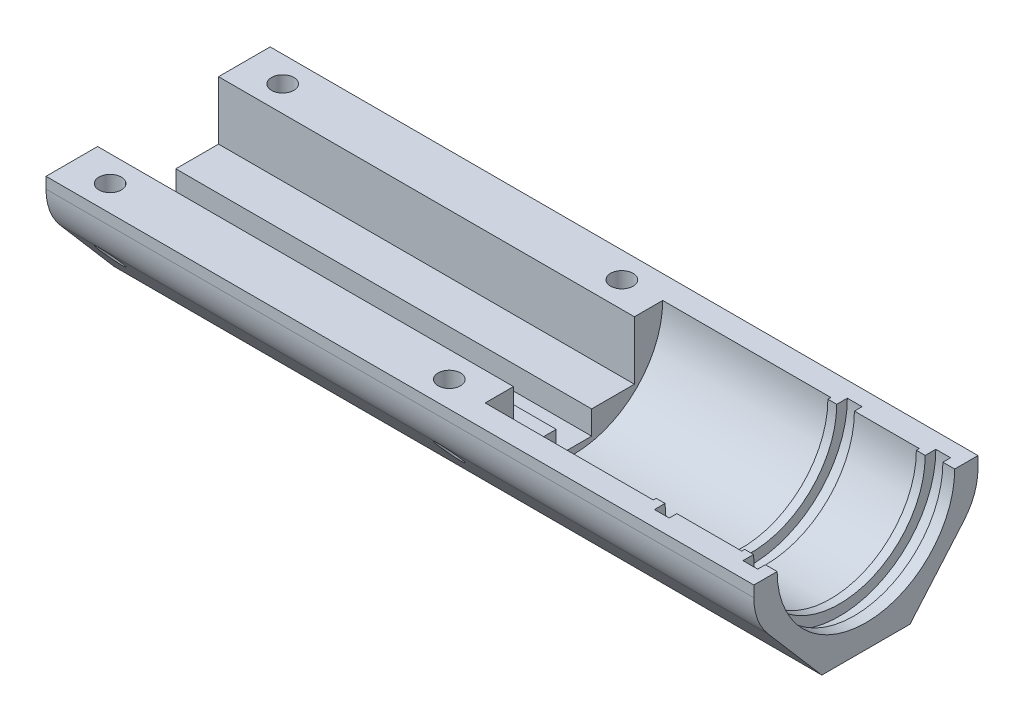
from build123d import *

# Parameters (mm, degrees)
R_VOLUTION1_ANGLE       = 180
ENL_V_START             = -19
ESQUISSE2_W             = 120
ESQUISSE2_H             = 50.1
ENL_V_MAT_EXTRU_1_DEPTH = 10
ESQUISSE3_W             = 146.438377439
ESQUISSE3_H             = 50.311635948
ENL_V_MAT_EXTRU_2_DEPTH = 10
ESQUISSE4_W             = 156.060048108
ESQUISSE4_H             = 43.154210134
ENL_V_MAT_EXTRU_3_DEPTH = 7
CONG_1_R                = 10
ENL_V_MAT_EXTRU_4_DEPTH = 121
ESQUISSE6_R             = 1.9
ENL_V_MAT_EXTRU_5_DEPTH = 20


with BuildPart() as part:
    # Esquisse1 → Révolution1 (revolve, symmetric)
    with BuildSketch(Plane.XY) as r_volution1_sk:
        Polygon((70.5, -15.05), (99, -15.05), (99, -14.55), (100.5, -14.55), (100.5, -15.05), (100.5, -16.35), (103, -16.35), (103, -15.05), (114, -15.05), (114, -14.55), (115.5, -14.55), (115.5, -15.05), (115.5, -16.35), (118, -16.35), (118, -15.05), (120, -15.05), (120, -25.05), (0, -25.05), (0, -15.05), (0, -9.55), (70.5, -9.55), align=None)
    revolve(axis=Axis((0, 0, 0), (1, 0, 0)), revolution_arc=R_VOLUTION1_ANGLE / 2)
    revolve(r_volution1_sk.sketch, axis=Axis((0, 0, 0), (-1, 0, 0)), revolution_arc=R_VOLUTION1_ANGLE / 2)

    # Esquisse2 → Enlèv. mat.-Extru.1 (cut)
    with BuildSketch(Plane(origin=(0, 0, 0), x_dir=(1, 0, 0), z_dir=(0, 1, 0)).offset(ENL_V_START)):
        with Locations((60, 0)):
            Rectangle(ESQUISSE2_W, ESQUISSE2_H)
    extrude(amount=-ENL_V_MAT_EXTRU_1_DEPTH, mode=Mode.SUBTRACT)

    # Esquisse3 → Enlèv. mat.-Extru.2 (cut)
    with BuildSketch(Plane.XY.offset(ENL_V_START)):
        with Locations((56.62202011, -13.21090671)):
            Rectangle(ESQUISSE3_W, ESQUISSE3_H)
    enl_v_mat_extru_2 = extrude(amount=-ENL_V_MAT_EXTRU_2_DEPTH, mode=Mode.SUBTRACT)

    # Esquisse4 → Enlèv. mat.-Extru.3 (cut)
    with BuildSketch(Plane(origin=(0, -16.324904288, -19), x_dir=(-1, 0, 0), z_dir=(0, -0.651692786, -0.758483034))):
        with Locations((-53.986796091, -2.160595236)):
            Rectangle(ESQUISSE4_W, ESQUISSE4_H)
    enl_v_mat_extru_3 = extrude(amount=-ENL_V_MAT_EXTRU_3_DEPTH, mode=Mode.SUBTRACT)

    # Symétrie1: Enlèv. mat.-Extru.2, Enlèv. mat.-Extru.3 across plane
    add(enl_v_mat_extru_2.mirror(Plane.XY), mode=Mode.SUBTRACT)
    add(enl_v_mat_extru_3.mirror(Plane.XY), mode=Mode.SUBTRACT)

    # Congé1
    cong_1_edges = [part.edges().sort_by_distance(p)[0] for p in [
        (60, -5.583646825, 19),
        (60, -5.583646825, -19),
    ]]
    fillet(cong_1_edges, radius=CONG_1_R)

    # Esquisse5 → Enlèv. mat.-Extru.4 (cut, through all)
    with BuildSketch(Plane.ZY):
        Polygon((10.25, 0), (-10.25, 0), (-10.25, -9.9), (-3, -9.9), (-3, -13.9), (3, -13.9), (3, -9.9), (10.25, -9.9), align=None)
    extrude(amount=-ENL_V_MAT_EXTRU_4_DEPTH, mode=Mode.SUBTRACT)

    # Esquisse6 → Enlèv. mat.-Extru.5 (cut, through all)
    with BuildSketch(Plane(origin=(0, 0, 0), x_dir=(1, 0, 0), z_dir=(0, 1, 0))):
        with Locations((6.5, 14.625)):
            Circle(ESQUISSE6_R)
        with Locations((64, 14.625)):
            Circle(ESQUISSE6_R)
    enl_v_mat_extru_5 = extrude(amount=-ENL_V_MAT_EXTRU_5_DEPTH, mode=Mode.SUBTRACT)

    # Symétrie2: Enlèv. mat.-Extru.5 across plane
    add(enl_v_mat_extru_5.mirror(Plane.XY), mode=Mode.SUBTRACT)


solid = part.part
